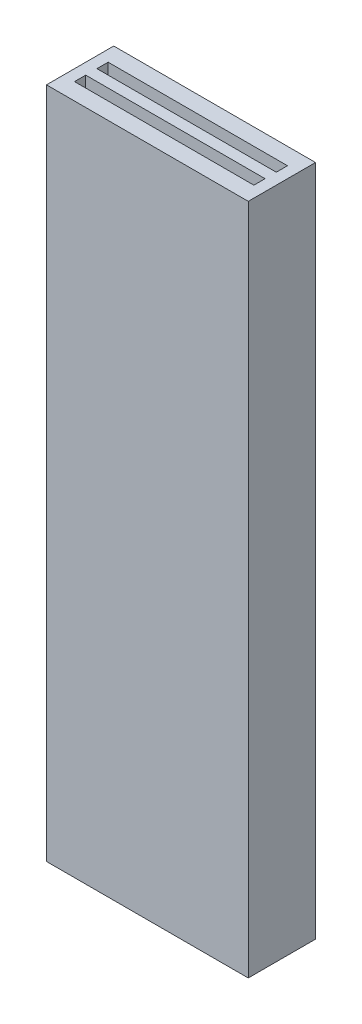
from build123d import *

# Parameters (mm, degrees)
SKETCH1_W           = 9
SKETCH1_H           = 3
BOSS_EXTRUDE1_DEPTH = 15
CUT_EXTRUDE1_START  = -31
SKETCH2_W           = 8
SKETCH2_H           = 0.5
CUT_EXTRUDE1_DEPTH  = 32


with BuildPart() as part:
    # Sketch1 → Boss-Extrude1 (new body, symmetric)
    with BuildSketch(Plane(origin=(0, 0, 0), x_dir=(1, 0, 0), z_dir=(0, 1, 0))):
        Rectangle(SKETCH1_W, SKETCH1_H)
    extrude(amount=BOSS_EXTRUDE1_DEPTH, both=True)

    # Sketch2 → Cut-Extrude1 (cut)
    with BuildSketch(Plane(origin=(0, 15, 0), x_dir=(1, 0, 0), z_dir=(0, 1, 0)).offset(CUT_EXTRUDE1_START)):
        with Locations((0, 0.5)):
            Rectangle(SKETCH2_W, SKETCH2_H)
    cut_extrude1 = extrude(amount=CUT_EXTRUDE1_DEPTH, mode=Mode.SUBTRACT)

    # Mirror1: Cut-Extrude1 across plane
    add(cut_extrude1.mirror(Plane.XY), mode=Mode.SUBTRACT)


solid = part.part
